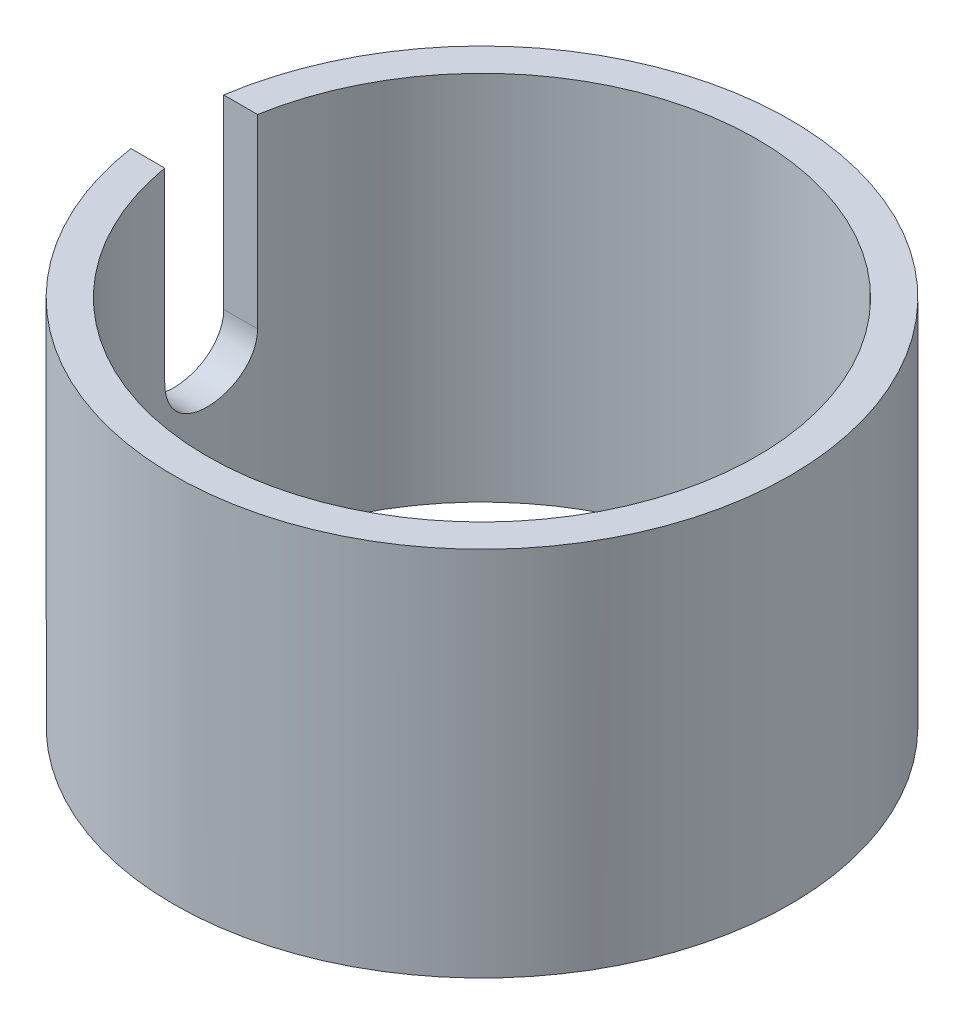
from build123d import *

# Parameters (mm, degrees)
SKETCH1_R           = 10.541
SKETCH1_R_2         = 9.398
BOSS_EXTRUDE1_DEPTH = 12.7
CUT_EXTRUDE1_DEPTH  = 12.7


with BuildPart() as part:
    # Sketch1 → Boss-Extrude1 (new body)
    with BuildSketch(Plane(origin=(0, 0, 0), x_dir=(1, 0, 0), z_dir=(0, 1, 0))):
        Circle(SKETCH1_R)
        Circle(SKETCH1_R_2, mode=Mode.SUBTRACT)
    extrude(amount=BOSS_EXTRUDE1_DEPTH)

    # Sketch2 → Cut-Extrude1 (cut)
    with BuildSketch(Plane(origin=(0, 0, 0), x_dir=(0, 0, -1), z_dir=(1, 0, 0))):
        with BuildLine():
            Line((-1.5875, 12.7), (1.5875, 12.7))
            Line((1.5875, 12.7), (1.5875, 6.35))
            ThreePointArc((1.5875, 6.35), (0, 4.7625), (-1.5875, 6.35))
            Line((-1.5875, 6.35), (-1.5875, 12.7))
        make_face()
    extrude(amount=-CUT_EXTRUDE1_DEPTH, mode=Mode.SUBTRACT)


solid = part.part
